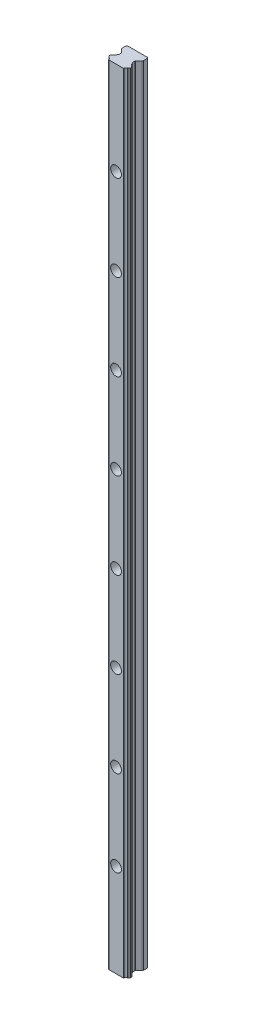
from build123d import *

# Parameters (mm, degrees)
AUFSATZ_LINEAR_AUSTRAGEN2_DEPTH                      = 275
STIRNSENKUNG_F_R_M4_ZYLINDERSCHRAUBE_MIT_D           = 4.5
STIRNSENKUNG_F_R_M4_ZYLINDERSCHRAUBE_MIT_CBORE_D     = 7.5
STIRNSENKUNG_F_R_M4_ZYLINDERSCHRAUBE_MIT_CBORE_DEPTH = 5.3
LINEARES_MUSTER1_COUNT                               = 5
LINEARES_MUSTER1_PITCH                               = 60
LINEARES_MUSTER1_COL_COUNT                           = 4
LINEARES_MUSTER1_COL_PITCH                           = 60


with BuildPart() as part:
    # Skizze20 → Aufsatz-Linear austragen2 (new body, symmetric)
    with BuildSketch(Plane(origin=(0, 0, 0), x_dir=(-1, 0, 0), z_dir=(0, 1, 0))):
        with BuildLine():
            Line((5.086058415, 14.962936516), (5.048994965, 14.999999966))
            Line((5.048994965, 14.999999966), (-5.048994935, 14.999999966))
            Line((-5.048994935, 14.999999966), (-5.086058385, 14.962936516))
            ThreePointArc((-5.086058385, 14.962936516), (-5.190484939, 14.907225244), (-5.274036713, 14.823393555))
            ThreePointArc((-5.274036713, 14.823393555), (-5.675619489, 13.981556013), (-6.478406056, 13.506695083))
            ThreePointArc((-6.478406056, 13.506695083), (-6.670526117, 13.397067183), (-6.775010631, 13.202102106))
            Line((-6.775010631, 13.202102106), (-6.80531374, 13.061185574))
            ThreePointArc((-6.80531374, 13.061185574), (-6.901163586, 12.875371344), (-7.077668811, 12.763299819))
            Line((-7.077668811, 12.763299819), (-7.218705101, 12.719471058))
            ThreePointArc((-7.218705101, 12.719471058), (-7.422088515, 12.574680309), (-7.49999998, 12.337490558))
            Line((-7.49999998, 12.337490558), (-7.49999998, 11.58151164))
            ThreePointArc((-7.49999998, 11.58151164), (-7.427329884, 11.351609192), (-7.23572431, 11.205241905))
            Line((-7.23572431, 11.205241905), (-7.060649561, 11.142090651))
            ThreePointArc((-7.060649561, 11.142090651), (-6.896592739, 11.030643995), (-6.806235234, 10.854092247))
            Line((-6.806235234, 10.854092247), (-6.774259003, 10.712764773))
            ThreePointArc((-6.774259003, 10.712764773), (-6.669188305, 10.520436279), (-6.47854359, 10.412340517))
            ThreePointArc((-6.47854359, 10.412340517), (-5.667573181, 9.928576079), (-5.270638873, 9.071753932))
            ThreePointArc((-5.270638873, 9.071753932), (-5.263507905, 8.797692466), (-5.081588111, 8.592593158))
            Line((-5.081588111, 8.592593158), (-4.887157216, 8.398162262))
            ThreePointArc((-4.887157216, 8.398162262), (-4.800448112, 8.268392918), (-4.769999924, 8.11531954))
            Line((-4.769999924, 8.11531954), (-4.769999924, 6.55325896))
            ThreePointArc((-4.769999924, 6.55325896), (-4.800448112, 6.400185582), (-4.887157216, 6.270416238))
            Line((-4.887157216, 6.270416238), (-7.207106753, 3.950466701))
            ThreePointArc((-7.207106753, 3.950466701), (-7.42387951, 3.626043343), (-7.49999998, 3.2433599))
            Line((-7.49999998, 3.2433599), (-7.49999998, 0.700000002))
            Line((-7.49999998, 0.700000002), (-6.800000016, 0))
            Line((-6.800000016, 0), (6.800000018, 0))
            Line((6.800000018, 0), (7.5, 0.699999983))
            Line((7.5, 0.699999983), (7.5, 3.24335988))
            ThreePointArc((7.5, 3.24335988), (7.423879531, 3.626043323), (7.207106773, 3.950466681))
            Line((7.207106773, 3.950466681), (4.887157237, 6.270416218))
            ThreePointArc((4.887157237, 6.270416218), (4.800448133, 6.400185562), (4.769999945, 6.553258941))
            Line((4.769999945, 6.553258941), (4.769999945, 8.11531952))
            ThreePointArc((4.769999945, 8.11531952), (4.800448133, 8.268392899), (4.887157237, 8.398162243))
            Line((4.887157237, 8.398162243), (5.081588132, 8.592593138))
            ThreePointArc((5.081588132, 8.592593138), (5.263507933, 8.797692455), (5.270638894, 9.071753931))
            ThreePointArc((5.270638894, 9.071753931), (5.667573202, 9.928576078), (6.478543611, 10.412340516))
            ThreePointArc((6.478543611, 10.412340516), (6.669188326, 10.520436278), (6.774259024, 10.712764772))
            Line((6.774259024, 10.712764772), (6.806235255, 10.854092246))
            ThreePointArc((6.806235255, 10.854092246), (6.89659276, 11.030643993), (7.060649582, 11.14209065))
            Line((7.060649582, 11.14209065), (7.235724331, 11.205241904))
            ThreePointArc((7.235724331, 11.205241904), (7.427329905, 11.351609191), (7.5, 11.581511639))
            Line((7.5, 11.581511639), (7.5, 12.337490557))
            ThreePointArc((7.5, 12.337490557), (7.422088535, 12.574680307), (7.218705121, 12.719471057))
            Line((7.218705121, 12.719471057), (7.077668832, 12.763299817))
            ThreePointArc((7.077668832, 12.763299817), (6.901163607, 12.875371342), (6.805313761, 13.061185572))
            Line((6.805313761, 13.061185572), (6.775010652, 13.202102105))
            ThreePointArc((6.775010652, 13.202102105), (6.670526139, 13.39706718), (6.478406079, 13.506695081))
            ThreePointArc((6.478406079, 13.506695081), (5.675619515, 13.981556013), (5.274036742, 14.823393555))
            ThreePointArc((5.274036742, 14.823393555), (5.190484969, 14.907225244), (5.086058415, 14.962936516))
        make_face()
    extrude(amount=AUFSATZ_LINEAR_AUSTRAGEN2_DEPTH, both=True)

    # Stirnsenkung für M4 Zylinderschraube mit Innensechskant1 (through all)
    with Locations(Plane(origin=(0, 0, 14.999999966), x_dir=(-1, 0, 0), z_dir=(0, 0, 1))):
        with Locations((1.5e-08, 30)):
            stirnsenkung_f_r_m4_zylinderschraube_mit = CounterBoreHole(STIRNSENKUNG_F_R_M4_ZYLINDERSCHRAUBE_MIT_D / 2, STIRNSENKUNG_F_R_M4_ZYLINDERSCHRAUBE_MIT_CBORE_D / 2, STIRNSENKUNG_F_R_M4_ZYLINDERSCHRAUBE_MIT_CBORE_DEPTH)

    # Lineares Muster1: Stirnsenkung für M4 Zylinderschraube mit Innensechskant1 ×5
    with Locations(*[(0, i * LINEARES_MUSTER1_PITCH, 0) for i in range(1, LINEARES_MUSTER1_COUNT)]):
        add(stirnsenkung_f_r_m4_zylinderschraube_mit, mode=Mode.SUBTRACT)

    # Lineares Muster1 col: Stirnsenkung für M4 Zylinderschraube mit Innensechskant1 ×4
    with Locations(*[(0, -i * LINEARES_MUSTER1_COL_PITCH, 0) for i in range(1, LINEARES_MUSTER1_COL_COUNT)]):
        add(stirnsenkung_f_r_m4_zylinderschraube_mit, mode=Mode.SUBTRACT)


solid = part.part
